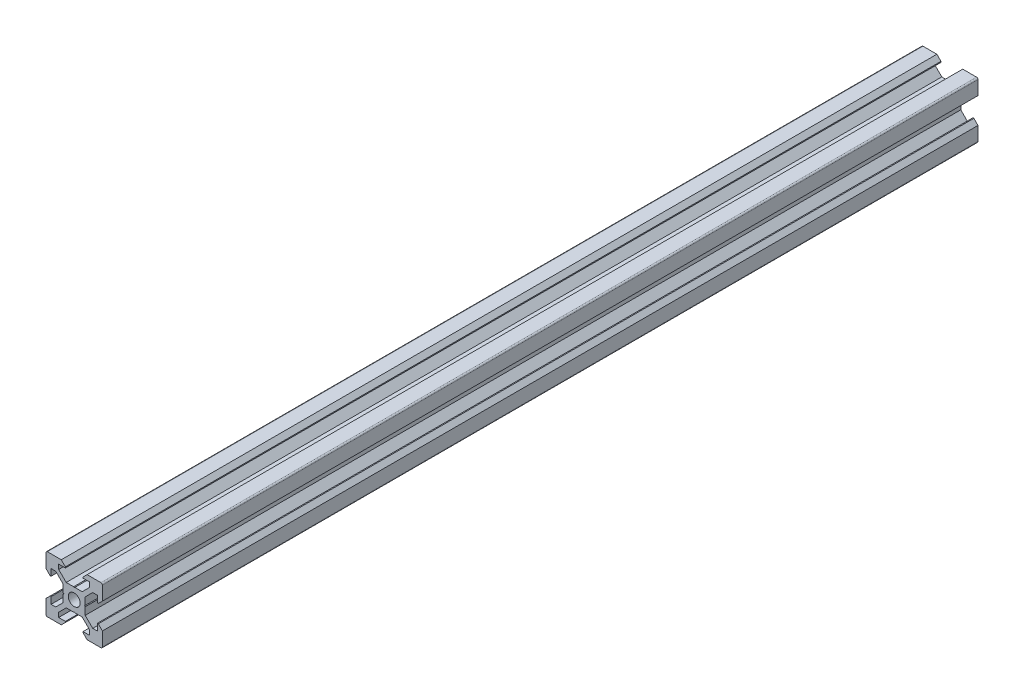
from build123d import *

# Parameters (mm, degrees)
SKETCH1_R           = 2.1
BOSS_EXTRUDE1_DEPTH = 310.45


with BuildPart() as part:
    # Sketch1 → Boss-Extrude1 (new body)
    with BuildSketch(Plane.XY):
        with BuildLine():
            Line((4.58, -10), (9.5, -10))
            ThreePointArc((9.5, -10), (9.853553391, -9.853553391), (10, -9.5))
            Line((10, -9.5), (10, -4.58))
            Line((10, -4.58), (8.545, -3.125))
            Line((8.545, -3.125), (8.2, -3.125))
            Line((8.2, -3.125), (8.2, -5.5))
            Line((8.2, -5.5), (6.560660172, -5.5))
            Line((6.560660172, -5.5), (3.9, -2.839339828))
            Line((3.9, -2.839339828), (3.9, -0.21))
            Line((3.9, -0.21), (3.69, 0))
            Line((3.69, 0), (3.9, 0.21))
            Line((3.9, 0.21), (3.9, 2.839339828))
            Line((3.9, 2.839339828), (6.560660172, 5.5))
            Line((6.560660172, 5.5), (8.2, 5.5))
            Line((8.2, 5.5), (8.2, 3.125))
            Line((8.2, 3.125), (8.545, 3.125))
            Line((8.545, 3.125), (10, 4.58))
            Line((10, 4.58), (10, 9.5))
            ThreePointArc((10, 9.5), (9.853553391, 9.853553391), (9.5, 10))
            Line((9.5, 10), (4.58, 10))
            Line((4.58, 10), (3.125, 8.545))
            Line((3.125, 8.545), (3.125, 8.2))
            Line((3.125, 8.2), (5.5, 8.2))
            Line((5.5, 8.2), (5.5, 6.560660172))
            Line((5.5, 6.560660172), (2.839339828, 3.9))
            Line((2.839339828, 3.9), (0.21, 3.9))
            Line((0.21, 3.9), (0, 3.69))
            Line((0, 3.69), (-0.21, 3.9))
            Line((-0.21, 3.9), (-2.839339828, 3.9))
            Line((-2.839339828, 3.9), (-5.5, 6.560660172))
            Line((-5.5, 6.560660172), (-5.5, 8.2))
            Line((-5.5, 8.2), (-3.125, 8.2))
            Line((-3.125, 8.2), (-3.125, 8.545))
            Line((-3.125, 8.545), (-4.58, 10))
            Line((-4.58, 10), (-9.5, 10))
            ThreePointArc((-9.5, 10), (-9.853553391, 9.853553391), (-10, 9.5))
            Line((-10, 9.5), (-10, 4.58))
            Line((-10, 4.58), (-8.545, 3.125))
            Line((-8.545, 3.125), (-8.2, 3.125))
            Line((-8.2, 3.125), (-8.2, 5.5))
            Line((-8.2, 5.5), (-6.560660172, 5.5))
            Line((-6.560660172, 5.5), (-3.9, 2.839339828))
            Line((-3.9, 2.839339828), (-3.9, 0.21))
            Line((-3.9, 0.21), (-3.69, 0))
            Line((-3.69, 0), (-3.9, -0.21))
            Line((-3.9, -0.21), (-3.9, -2.839339828))
            Line((-3.9, -2.839339828), (-6.560660172, -5.5))
            Line((-6.560660172, -5.5), (-8.2, -5.5))
            Line((-8.2, -5.5), (-8.2, -3.125))
            Line((-8.2, -3.125), (-8.545, -3.125))
            Line((-8.545, -3.125), (-10, -4.58))
            Line((-10, -4.58), (-10, -9.5))
            ThreePointArc((-10, -9.5), (-9.853553391, -9.853553391), (-9.5, -10))
            Line((-9.5, -10), (-4.58, -10))
            Line((-4.58, -10), (-3.125, -8.545))
            Line((-3.125, -8.545), (-3.125, -8.2))
            Line((-3.125, -8.2), (-5.5, -8.2))
            Line((-5.5, -8.2), (-5.5, -6.560660172))
            Line((-5.5, -6.560660172), (-2.839339828, -3.9))
            Line((-2.839339828, -3.9), (-0.21, -3.9))
            Line((-0.21, -3.9), (0, -3.69))
            Line((0, -3.69), (0.21, -3.9))
            Line((0.21, -3.9), (2.839339828, -3.9))
            Line((2.839339828, -3.9), (5.5, -6.560660172))
            Line((5.5, -6.560660172), (5.5, -8.2))
            Line((5.5, -8.2), (3.125, -8.2))
            Line((3.125, -8.2), (3.125, -8.545))
            Line((3.125, -8.545), (4.58, -10))
        make_face()
        Circle(SKETCH1_R, mode=Mode.SUBTRACT)
    extrude(amount=BOSS_EXTRUDE1_DEPTH)


solid = part.part
